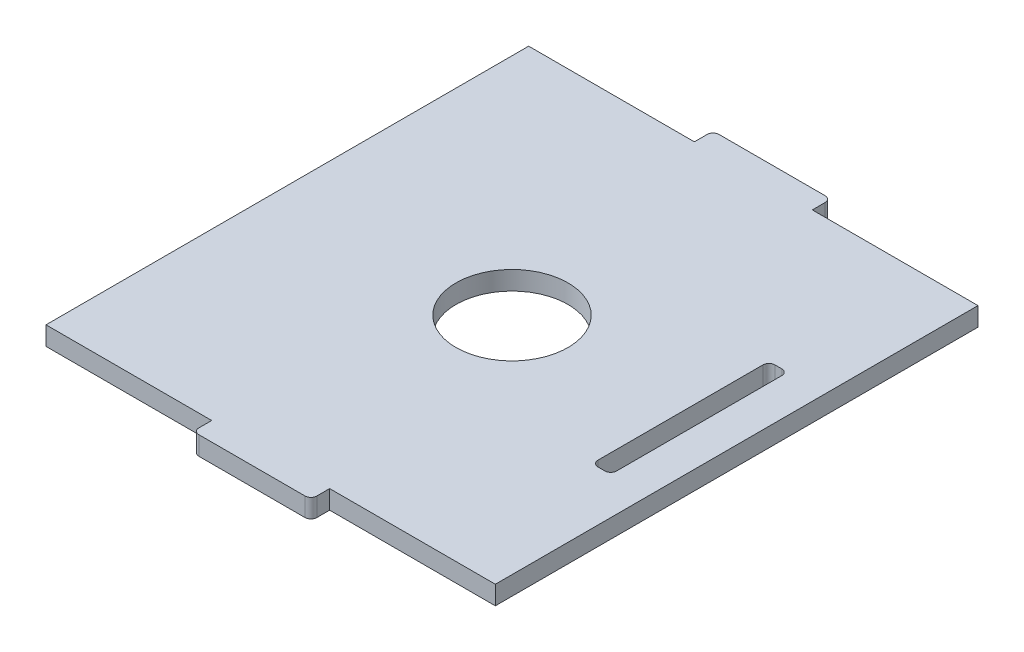
from build123d import *

# Parameters (mm, degrees)
BOSS_EXTRUDE1_DEPTH = 3.175
SKETCH2_R           = 9.5
SKETCH2_W           = 3.175
SKETCH2_H           = 30
CUT_EXTRUDE1_DEPTH  = 4.175
FILLET1_R           = 1


with BuildPart() as part:
    # Sketch1 → Boss-Extrude1 (new body)
    with BuildSketch(Plane(origin=(0, 0, 0), x_dir=(1, 0, 0), z_dir=(0, 1, 0))):
        Polygon((-38.1, -40.925), (-10, -40.925), (-10, -44.1), (10, -44.1), (10, -40.925), (38.1, -40.925), (38.1, 40.925), (10, 40.925), (10, 44.1), (-10, 44.1), (-10, 40.925), (-38.1, 40.925), align=None)
    extrude(amount=BOSS_EXTRUDE1_DEPTH)

    # Sketch2 → Cut-Extrude1 (cut, through all)
    with BuildSketch(Plane(origin=(0, 3.175, 0), x_dir=(1, 0, 0), z_dir=(0, 1, 0))):
        Circle(SKETCH2_R)
        with Locations((30.1625, 0)):
            Rectangle(SKETCH2_W, SKETCH2_H)
    extrude(amount=-CUT_EXTRUDE1_DEPTH, mode=Mode.SUBTRACT)

    # Fillet1
    fillet1_edges = [part.edges().sort_by_distance(p)[0] for p in [
        (10, 1.5875, 44.1),
        (-10, 1.5875, 44.1),
        (-10, 1.5875, -44.1),
        (10, 1.5875, -44.1),
        (28.575, 1.5875, 15),
        (28.575, 1.5875, -15),
        (31.75, 1.5875, -15),
        (31.75, 1.5875, 15),
    ]]
    fillet(fillet1_edges, radius=FILLET1_R)


solid = part.part
